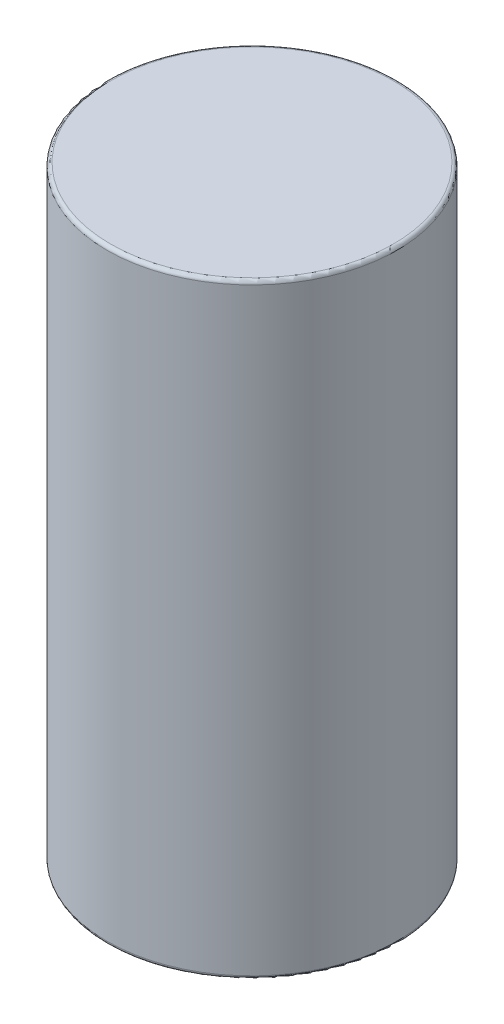
from build123d import *

# Parameters (mm, degrees)
SKETCH_1_R      = 4
EXTRUDE_1_DEPTH = 16.7
FILLET_1_R      = 0.1
FILLET_2_R      = 0.1


with BuildPart() as part:
    # Эскиз1 → Бобышка-Вытянуть1 (new body)
    with BuildSketch(Plane(origin=(0, 0, 0), x_dir=(1, 0, 0), z_dir=(0, 1, 0))):
        Circle(SKETCH_1_R)
    extrude(amount=EXTRUDE_1_DEPTH)

    # Скругление1
    fillet_1_edges = [part.edges().sort_by_distance(p)[0] for p in [
        (-4, 16.7, 0),
    ]]
    fillet(fillet_1_edges, radius=FILLET_1_R)

    # Скругление2
    fillet_2_edges = [part.edges().sort_by_distance(p)[0] for p in [
        (-4, 0, 0),
    ]]
    fillet(fillet_2_edges, radius=FILLET_2_R)


solid = part.part
